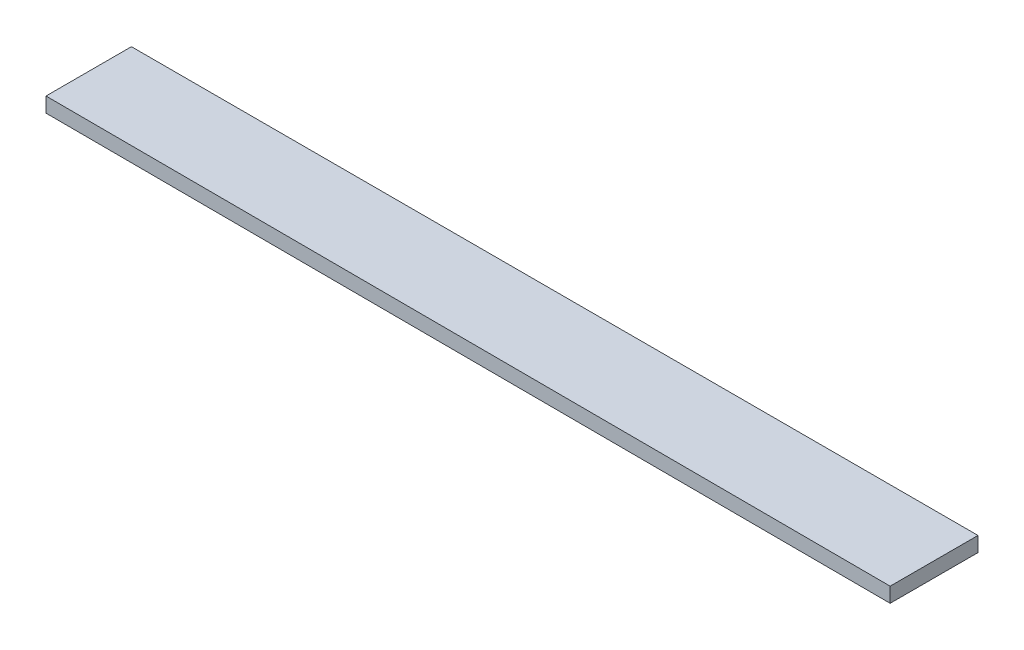
from build123d import *

# Parameters (mm, degrees)
BOSS_EXTRU_1_DEPTH = 2


with BuildPart() as part:
    # Esquisse1 → Boss.-Extru.1 (new body)
    with BuildSketch(Plane(origin=(0, 0, 0), x_dir=(1, 0, 0), z_dir=(0, 1, 0))):
        Polygon((113.836220673, -0.325885337), (113.836220673, 11.488054861), (0, 11.488054861), (0, 0), align=None)
    extrude(amount=BOSS_EXTRU_1_DEPTH)


solid = part.part
